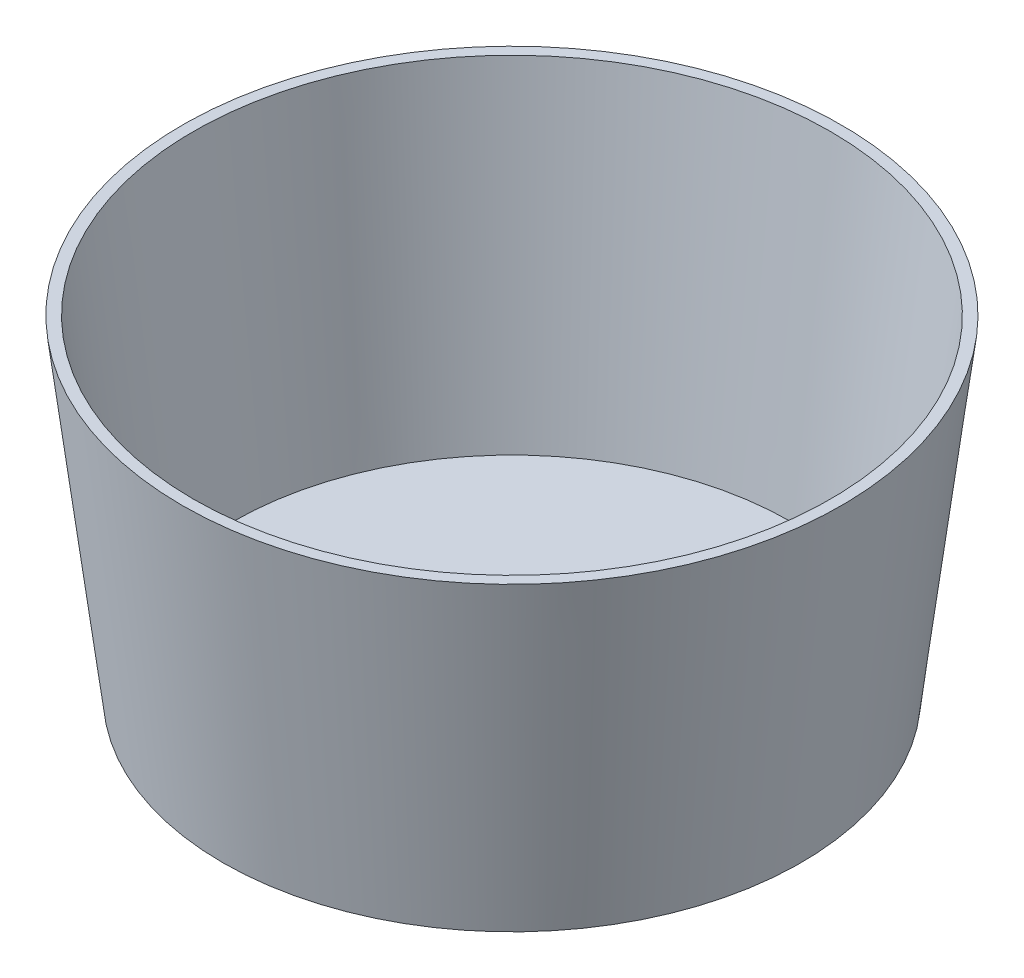
from build123d import *

# Parameters (mm, degrees)
SKETCH1_R           = 300
BOSS_EXTRUDE1_DEPTH = 300
BOSS_EXTRUDE1_DRAFT = -7
SHELL2_T            = -10


with BuildPart() as part:
    # Sketch1 → Boss-Extrude1 (with draft: the straight prism first)
    with BuildSketch(Plane(origin=(0, 0, 0), x_dir=(1, 0, 0), z_dir=(0, 1, 0))):
        Circle(SKETCH1_R)
    extrude(amount=-BOSS_EXTRUDE1_DEPTH)
    # Boss-Extrude1: the draft: its side faces are tilted about the plane it starts from
    boss_extrude1_sides = [part.faces().sort_by_distance(p)[0] for p in [
        (-300, -150, 0),
    ]]
    draft(boss_extrude1_sides, Plane(origin=(0, 0, 0), x_dir=(1, 0, 0), z_dir=(0, 1, 0)), BOSS_EXTRUDE1_DRAFT)

    # Shell2
    shell2_openings = [part.faces().sort_by_distance(p)[0] for p in [
        (0, 0, 0),
    ]]
    offset(amount=SHELL2_T, openings=shell2_openings, kind=Kind.INTERSECTION)


solid = part.part
